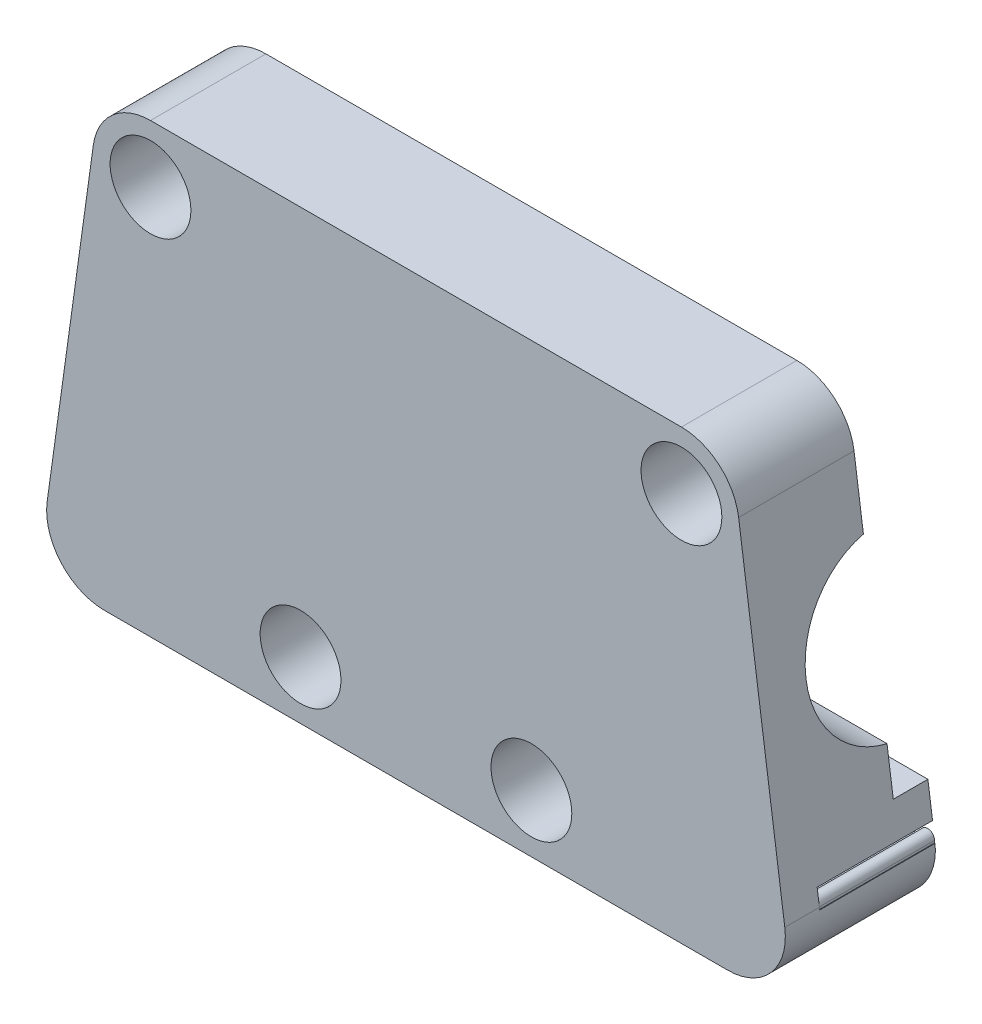
from build123d import *

# Parameters (mm, degrees)
SKETCH1_R               = 2
BOSS_EXTRUDE1_DEPTH     = 10
SKETCH2_R               = 5
CUT_EXTRUDE1_DEPTH      = 33
CUT_EXTRUDE1_DEPTH_BACK = 33
SKETCH3_R               = 7.5
CUT_EXTRUDE2_DEPTH      = 16
SKETCH4_R               = 3.5
CUT_EXTRUDE3_DEPTH      = 8
CUT_EXTRUDE4_DEPTH      = 7
BOSS_EXTRUDE2_START     = -10
BOSS_EXTRUDE2_DEPTH     = 7
LPATTERN1_COUNT         = 6
LPATTERN1_PITCH         = 2
LPATTERN2_COUNT         = 2
LPATTERN2_PITCH         = 52.6
LPATTERN2_START         = -10
LPATTERN2_COPY_1_DEPTH  = 7
LPATTERN2_COPY_2_DEPTH  = 7
LPATTERN2_COPY_3_DEPTH  = 7
LPATTERN2_COPY_4_DEPTH  = 7
LPATTERN2_COPY_5_DEPTH  = 7
FILLET1_R               = 5
FILLET2_R               = 1
SKETCH8_R               = 2
BOSS_EXTRUDE3_DEPTH     = 3


with BuildPart() as part:
    # Sketch1 → Boss-Extrude1 (new body)
    with BuildSketch(Plane.XY):
        with BuildLine():
            Line((-27, -21.25), (27, -21.25))
            ThreePointArc((27, -21.25), (30.771278101, -19.532904428), (31.952298231, -15.560984594))
            Line((31.952298231, -15.560984594), (27.952298231, 13.189015406))
            ThreePointArc((27.952298231, 13.189015406), (26.282904428, 16.271278101), (23, 17.5))
            Line((23, 17.5), (-23, 17.5))
            ThreePointArc((-23, 17.5), (-26.282904428, 16.271278101), (-27.952298231, 13.189015406))
            Line((-27.952298231, 13.189015406), (-31.952298231, -15.560984594))
            ThreePointArc((-31.952298231, -15.560984594), (-30.771278101, -19.532904428), (-27, -21.25))
        make_face()
        with Locations((-10, -16.25)):
            Circle(SKETCH1_R, mode=Mode.SUBTRACT)
        with Locations((10, -16.25)):
            Circle(SKETCH1_R, mode=Mode.SUBTRACT)
        with Locations((23, 12.5)):
            Circle(SKETCH1_R, mode=Mode.SUBTRACT)
        with Locations((-23, 12.5)):
            Circle(SKETCH1_R, mode=Mode.SUBTRACT)
    extrude(amount=BOSS_EXTRUDE1_DEPTH)

    # Sketch2 → Cut-Extrude1 (cut, two sides)
    with BuildSketch(Plane(origin=(0, 0, 0), x_dir=(0, 0, -1), z_dir=(1, 0, 0))) as cut_extrude1_sk:
        with Locations((1.5, 0)):
            Circle(SKETCH2_R)
    extrude(amount=CUT_EXTRUDE1_DEPTH, mode=Mode.SUBTRACT)
    extrude(cut_extrude1_sk.sketch, amount=-CUT_EXTRUDE1_DEPTH_BACK, mode=Mode.SUBTRACT)

    # Sketch3 → Cut-Extrude2 (cut)
    with BuildSketch(Plane(origin=(15, 0, 0), x_dir=(0, 0, -1), z_dir=(1, 0, 0))):
        with Locations((1.5, 0)):
            Circle(SKETCH3_R)
    cut_extrude2 = extrude(amount=CUT_EXTRUDE2_DEPTH, mode=Mode.SUBTRACT)

    # Mirror1: Cut-Extrude2 across plane
    add(cut_extrude2.mirror(Plane(origin=(0, 0, 0), x_dir=(0, 0, 1), z_dir=(1, 0, 0))), mode=Mode.SUBTRACT)

    # Sketch4 → Cut-Extrude3 (cut)
    with BuildSketch(Plane.XY.offset(10)):
        with Locations((10, -16.25)):
            Circle(SKETCH4_R)
        with Locations((-10, -16.25)):
            Circle(SKETCH4_R)
        with Locations((23, 12.5)):
            Circle(SKETCH4_R)
        with Locations((-23, 12.5)):
            Circle(SKETCH4_R)
    extrude(amount=-CUT_EXTRUDE3_DEPTH, mode=Mode.SUBTRACT)

    # Sketch6 → Cut-Extrude4 (cut)
    with BuildSketch(Plane(origin=(0, 0, 0), x_dir=(-1, 0, 0), z_dir=(0, 0, -1))):
        Polygon((-31.974937186, -15.75), (-20.589119642, -15.75), (-14.48075081, -21.25), (-12.08958833, -21.25), (-19.974937186, -14.15), (-31.974937186, -14.15), align=None)
        Polygon((20.589119642, -15.75), (14.48075081, -21.25), (12.08958833, -21.25), (19.974937186, -14.15), (31.974937186, -14.15), (31.974937186, -15.75), align=None)
    extrude(amount=-CUT_EXTRUDE4_DEPTH, mode=Mode.SUBTRACT)

    # Sketch7 → Boss-Extrude2 (add)
    with BuildSketch(Plane.XY.offset(10).offset(BOSS_EXTRUDE2_START)):
        with BuildLine():
            Line((30.724937186, -15.75), (31.924937186, -15.75))
            Line((31.924937186, -15.75), (31.924937186, -15.55))
            ThreePointArc((31.924937186, -15.55), (31.324937186, -14.95), (30.724937186, -15.55))
            Line((30.724937186, -15.55), (30.724937186, -15.75))
        make_face()
    boss_extrude2 = extrude(amount=BOSS_EXTRUDE2_DEPTH)

    # LPattern1: Boss-Extrude2 ×6
    with Locations(*[(-i * LPATTERN1_PITCH, 0, 0) for i in range(1, LPATTERN1_COUNT)]):
        add(boss_extrude2)

    # LPattern2: Boss-Extrude2 ×2
    with Locations(*[(-i * LPATTERN2_PITCH, 0, 0) for i in range(1, LPATTERN2_COUNT)]):
        add(boss_extrude2)

    # LPattern2 copy 1 sketch → LPattern2 copy 1 (add)
    with BuildSketch(Plane(origin=(-54.6, 0, 10), x_dir=(1, 0, 0), z_dir=(0, 0, 1)).offset(LPATTERN2_START)):
        with BuildLine():
            Line((30.724937186, -15.75), (31.924937186, -15.75))
            Line((31.924937186, -15.75), (31.924937186, -15.55))
            ThreePointArc((31.924937186, -15.55), (31.324937186, -14.95), (30.724937186, -15.55))
            Line((30.724937186, -15.55), (30.724937186, -15.75))
        make_face()
    extrude(amount=LPATTERN2_COPY_1_DEPTH)

    # LPattern2 copy 2 sketch → LPattern2 copy 2 (add)
    with BuildSketch(Plane(origin=(-56.6, 0, 10), x_dir=(1, 0, 0), z_dir=(0, 0, 1)).offset(LPATTERN2_START)):
        with BuildLine():
            Line((30.724937186, -15.75), (31.924937186, -15.75))
            Line((31.924937186, -15.75), (31.924937186, -15.55))
            ThreePointArc((31.924937186, -15.55), (31.324937186, -14.95), (30.724937186, -15.55))
            Line((30.724937186, -15.55), (30.724937186, -15.75))
        make_face()
    extrude(amount=LPATTERN2_COPY_2_DEPTH)

    # LPattern2 copy 3 sketch → LPattern2 copy 3 (add)
    with BuildSketch(Plane(origin=(-58.6, 0, 10), x_dir=(1, 0, 0), z_dir=(0, 0, 1)).offset(LPATTERN2_START)):
        with BuildLine():
            Line((30.724937186, -15.75), (31.924937186, -15.75))
            Line((31.924937186, -15.75), (31.924937186, -15.55))
            ThreePointArc((31.924937186, -15.55), (31.324937186, -14.95), (30.724937186, -15.55))
            Line((30.724937186, -15.55), (30.724937186, -15.75))
        make_face()
    extrude(amount=LPATTERN2_COPY_3_DEPTH)

    # LPattern2 copy 4 sketch → LPattern2 copy 4 (add)
    with BuildSketch(Plane(origin=(-60.6, 0, 10), x_dir=(1, 0, 0), z_dir=(0, 0, 1)).offset(LPATTERN2_START)):
        with BuildLine():
            Line((30.724937186, -15.75), (31.924937186, -15.75))
            Line((31.924937186, -15.75), (31.924937186, -15.55))
            ThreePointArc((31.924937186, -15.55), (31.324937186, -14.95), (30.724937186, -15.55))
            Line((30.724937186, -15.55), (30.724937186, -15.75))
        make_face()
    extrude(amount=LPATTERN2_COPY_4_DEPTH)

    # LPattern2 copy 5 sketch → LPattern2 copy 5 (add)
    with BuildSketch(Plane(origin=(-62.6, 0, 10), x_dir=(1, 0, 0), z_dir=(0, 0, 1)).offset(LPATTERN2_START)):
        with BuildLine():
            Line((30.724937186, -15.75), (31.924937186, -15.75))
            Line((31.924937186, -15.75), (31.924937186, -15.55))
            ThreePointArc((31.924937186, -15.55), (31.324937186, -14.95), (30.724937186, -15.55))
            Line((30.724937186, -15.55), (30.724937186, -15.75))
        make_face()
    extrude(amount=LPATTERN2_COPY_5_DEPTH)

    # Fillet1
    fillet1_edges = [part.edges().sort_by_distance(p)[0] for p in [
        (12.08958833, -21.25, 3.5),
        (-12.08958833, -21.25, 3.5),
    ]]
    fillet(fillet1_edges, radius=FILLET1_R)

    # Fillet2
    fillet2_edges = [part.edges().sort_by_distance(p)[0] for p in [
        (14.48075081, -21.25, 3.5),
        (-14.48075081, -21.25, 3.5),
    ]]
    fillet(fillet2_edges, radius=FILLET2_R)

    # Sketch8 → Boss-Extrude3 (add)
    with BuildSketch(Plane(origin=(0, 0, 0), x_dir=(-1, 0, 0), z_dir=(0, 0, -1))):
        with BuildLine():
            Line((-31.924937186, -15.75), (-31.974937186, -15.75))
            ThreePointArc((-31.974937186, -15.75), (-30.708099244, -19.604101966), (-27, -21.25))
            Line((-27, -21.25), (-17.085839875, -21.25))
            ThreePointArc((-17.085839875, -21.25), (-16.152259448, -20.60836795), (-16.416709268, -19.506855175))
            Line((-16.416709268, -19.506855175), (-20.589119642, -15.75))
            Line((-20.589119642, -15.75), (-20.724937186, -15.75))
            Line((-20.724937186, -15.75), (-20.724937186, -15.55))
            ThreePointArc((-20.724937186, -15.55), (-21.324937186, -14.95), (-21.924937186, -15.55))
            Line((-21.924937186, -15.55), (-21.924937186, -15.75))
            Line((-21.924937186, -15.75), (-22.724937186, -15.75))
            Line((-22.724937186, -15.75), (-22.724937186, -15.55))
            ThreePointArc((-22.724937186, -15.55), (-23.324937186, -14.95), (-23.924937186, -15.55))
            Line((-23.924937186, -15.55), (-23.924937186, -15.75))
            Line((-23.924937186, -15.75), (-24.724937186, -15.75))
            Line((-24.724937186, -15.75), (-24.724937186, -15.55))
            ThreePointArc((-24.724937186, -15.55), (-25.324937186, -14.95), (-25.924937186, -15.55))
            Line((-25.924937186, -15.55), (-25.924937186, -15.75))
            Line((-25.924937186, -15.75), (-26.724937186, -15.75))
            Line((-26.724937186, -15.75), (-26.724937186, -15.55))
            ThreePointArc((-26.724937186, -15.55), (-27.324937186, -14.95), (-27.924937186, -15.55))
            Line((-27.924937186, -15.55), (-27.924937186, -15.75))
            Line((-27.924937186, -15.75), (-28.724937186, -15.75))
            Line((-28.724937186, -15.75), (-28.724937186, -15.55))
            ThreePointArc((-28.724937186, -15.55), (-29.324937186, -14.95), (-29.924937186, -15.55))
            Line((-29.924937186, -15.55), (-29.924937186, -15.75))
            Line((-29.924937186, -15.75), (-30.724937186, -15.75))
            Line((-30.724937186, -15.75), (-30.724937186, -15.55))
            ThreePointArc((-30.724937186, -15.55), (-31.324937186, -14.95), (-31.924937186, -15.55))
            Line((-31.924937186, -15.55), (-31.924937186, -15.75))
        make_face()
        with BuildLine():
            Line((-31.755987331, -14.15), (-19.974937186, -14.15))
            Line((-19.974937186, -14.15), (-13.515921187, -19.965724127))
            ThreePointArc((-13.515921187, -19.965724127), (-11.962107903, -20.917902132), (-10.170268155, -21.25))
            Line((-10.170268155, -21.25), (10.170268155, -21.25))
            ThreePointArc((10.170268155, -21.25), (11.962107903, -20.917902132), (13.515921187, -19.965724127))
            Line((13.515921187, -19.965724127), (19.974937186, -14.15))
            Line((19.974937186, -14.15), (31.755987331, -14.15))
            Line((31.755987331, -14.15), (31.35250907, -11.25))
            Line((31.35250907, -11.25), (-31.35250907, -11.25))
            Line((-31.35250907, -11.25), (-31.755987331, -14.15))
        make_face()
        with Locations((-10, -16.25)):
            Circle(SKETCH8_R, mode=Mode.SUBTRACT)
        with Locations((10, -16.25)):
            Circle(SKETCH8_R, mode=Mode.SUBTRACT)
        with BuildLine():
            Line((21.875062814, -15.75), (21.875062814, -15.55))
            ThreePointArc((21.875062814, -15.55), (21.275062814, -14.95), (20.675062814, -15.55))
            Line((20.675062814, -15.55), (20.675062814, -15.75))
            Line((20.675062814, -15.75), (20.589119642, -15.75))
            Line((20.589119642, -15.75), (16.416709268, -19.506855175))
            ThreePointArc((16.416709268, -19.506855175), (16.152259448, -20.60836795), (17.085839875, -21.25))
            Line((17.085839875, -21.25), (27, -21.25))
            ThreePointArc((27, -21.25), (30.708099244, -19.604101966), (31.974937186, -15.75))
            Line((31.974937186, -15.75), (31.875062814, -15.75))
            Line((31.875062814, -15.75), (31.875062814, -15.55))
            ThreePointArc((31.875062814, -15.55), (31.275062814, -14.95), (30.675062814, -15.55))
            Line((30.675062814, -15.55), (30.675062814, -15.75))
            Line((30.675062814, -15.75), (29.875062814, -15.75))
            Line((29.875062814, -15.75), (29.875062814, -15.55))
            ThreePointArc((29.875062814, -15.55), (29.275062814, -14.95), (28.675062814, -15.55))
            Line((28.675062814, -15.55), (28.675062814, -15.75))
            Line((28.675062814, -15.75), (27.875062814, -15.75))
            Line((27.875062814, -15.75), (27.875062814, -15.55))
            ThreePointArc((27.875062814, -15.55), (27.275062814, -14.95), (26.675062814, -15.55))
            Line((26.675062814, -15.55), (26.675062814, -15.75))
            Line((26.675062814, -15.75), (25.875062814, -15.75))
            Line((25.875062814, -15.75), (25.875062814, -15.55))
            ThreePointArc((25.875062814, -15.55), (25.275062814, -14.95), (24.675062814, -15.55))
            Line((24.675062814, -15.55), (24.675062814, -15.75))
            Line((24.675062814, -15.75), (23.875062814, -15.75))
            Line((23.875062814, -15.75), (23.875062814, -15.55))
            ThreePointArc((23.875062814, -15.55), (23.275062814, -14.95), (22.675062814, -15.55))
            Line((22.675062814, -15.55), (22.675062814, -15.75))
            Line((22.675062814, -15.75), (21.875062814, -15.75))
        make_face()
    extrude(amount=BOSS_EXTRUDE3_DEPTH)


solid = part.part
